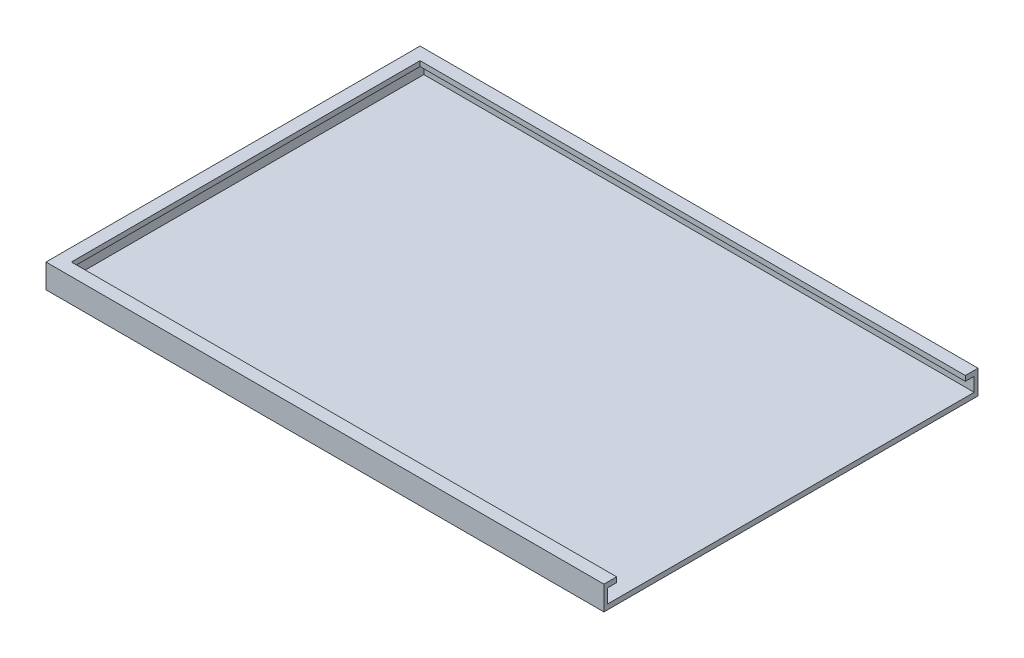
from build123d import *

# Parameters (mm, degrees)
SKETCH_1_W          = 86
SKETCH_1_H          = 55
EXTRUDE_311_DEPTH   = 0.8
SKETCH_2_W          = 88
SKETCH_2_H          = 3.8
EXTRUDE_1_DEPTH     = 2
SKETCH_3_W          = 87.2
SKETCH_3_H          = 2.2
CUT_EXTRUDE_1_DEPTH = 1.4
SKETCH_4_W          = 59
SKETCH_4_H          = 3.8
EXTRUDE_2_DEPTH     = 2
SKETCH_5_W          = 57.8
SKETCH_5_H          = 2.2
CUT_EXTRUDE_2_DEPTH = 0.8


with BuildPart() as part:
    # Эскиз1 → Extrude 311 (new body)
    with BuildSketch(Plane(origin=(0, 0, 0), x_dir=(1, 0, 0), z_dir=(0, 1, 0))):
        Rectangle(SKETCH_1_W, SKETCH_1_H)
    extrude(amount=EXTRUDE_311_DEPTH)

    # Эскиз2 → Бобышка-Вытянуть1 (add)
    with BuildSketch(Plane(origin=(0, 0, -27.5), x_dir=(-1, 0, 0), z_dir=(0, 0, -1))):
        with Locations((1, 1.9)):
            Rectangle(SKETCH_2_W, SKETCH_2_H)
    extrude_1 = extrude(amount=EXTRUDE_1_DEPTH)

    # Эскиз3 → Вырез-Вытянуть1 (cut)
    with BuildSketch(Plane.XY.offset(-27.5)):
        with Locations((-0.6, 1.9)):
            Rectangle(SKETCH_3_W, SKETCH_3_H)
    cut_extrude_1 = extrude(amount=-CUT_EXTRUDE_1_DEPTH, mode=Mode.SUBTRACT)

    # Зеркальное отражение1: Бобышка-Вытянуть1, Вырез-Вытянуть1 across plane
    add(extrude_1.mirror(Plane.XY))
    add(cut_extrude_1.mirror(Plane.XY), mode=Mode.SUBTRACT)

    # Эскиз4 → Бобышка-Вытянуть2 (add)
    with BuildSketch(Plane.ZY.offset(43)):
        with Locations((0, 1.9)):
            Rectangle(SKETCH_4_W, SKETCH_4_H)
    extrude(amount=EXTRUDE_2_DEPTH)

    # Эскиз5 → Вырез-Вытянуть2 (cut)
    with BuildSketch(Plane(origin=(-43, 0, 0), x_dir=(0, 0, -1), z_dir=(1, 0, 0))):
        with Locations((0, 1.9)):
            Rectangle(SKETCH_5_W, SKETCH_5_H)
    extrude(amount=-CUT_EXTRUDE_2_DEPTH, mode=Mode.SUBTRACT)


solid = part.part
